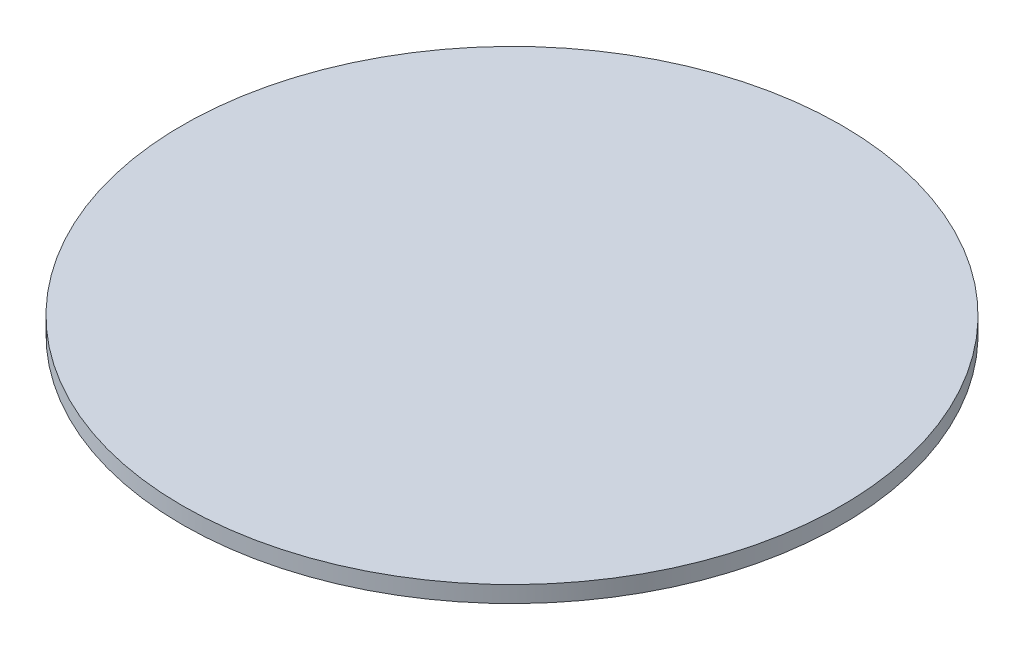
from build123d import *

# Parameters (mm, degrees)
ESQUISSE1_R      = 200
EXTRUSION1_DEPTH = 10


with BuildPart() as part:
    # Esquisse1 → Extrusion1 (new body)
    with BuildSketch(Plane(origin=(0, 0, 0), x_dir=(1, 0, 0), z_dir=(0, 1, 0))):
        Circle(ESQUISSE1_R)
    extrude(amount=EXTRUSION1_DEPTH)


solid = part.part
